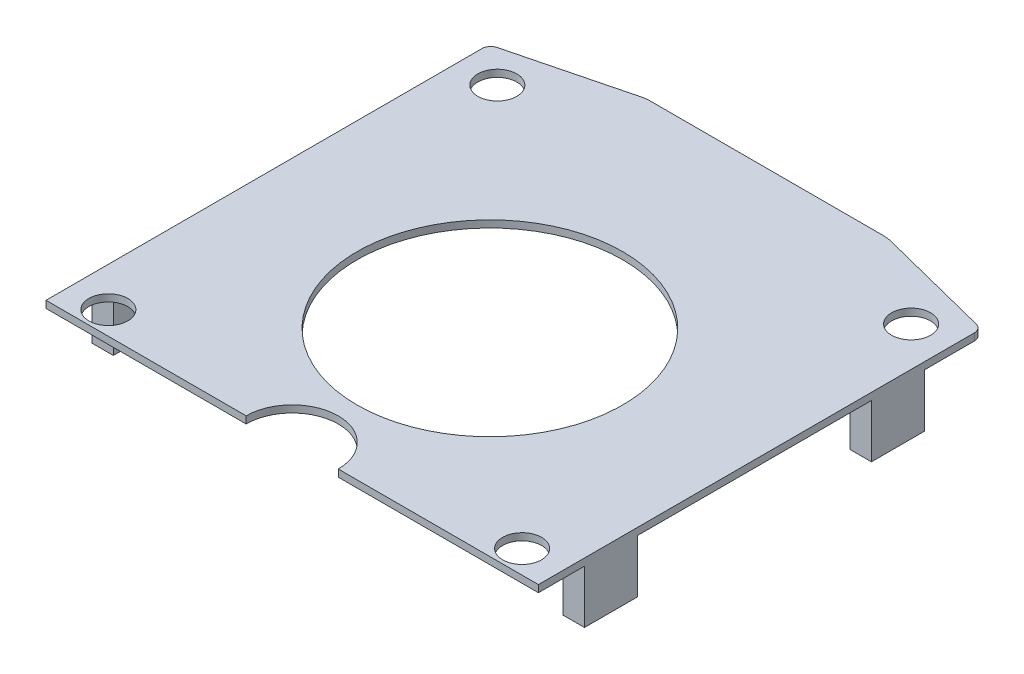
from build123d import *

# Parameters (mm, degrees)
SKETCH1_W           = 13.9
SKETCH1_H           = 0.75
BOSS_EXTRUDE1_DEPTH = 0.2
SKETCH2_R           = 0.55
SKETCH2_R_2         = 3.75
CUT_EXTRUDE1_DEPTH  = 0.3
CUT_EXTRUDE2_DEPTH  = 0.3
SKETCH6_W           = 1.5
SKETCH6_H           = 1.5
BOSS_EXTRUDE2_DEPTH = 0.6
SKETCH7_W           = 0.6
SKETCH7_H           = 1.5
BOSS_EXTRUDE3_DEPTH = 1.5


with BuildPart() as part:
    # Sketch1 → Boss-Extrude1 (new body)
    with BuildSketch(Plane(origin=(0, 0, 0), x_dir=(1, 0, 0), z_dir=(0, 1, 0))):
        with BuildLine():
            Line((-13.9, 12.65), (0, 12.65))
            Line((0, 12.65), (0, 24.20560625))
            ThreePointArc((0, 24.20560625), (-0.052642553, 24.359066467), (-0.188400305, 24.447898383))
            Line((-0.188400305, 24.447898383), (-3.418729556, 25.269168531))
            ThreePointArc((-3.418729556, 25.269168531), (-3.540968219, 25.292262196), (-3.665128335, 25.3))
            Line((-3.665128335, 25.3), (-10.234871665, 25.3))
            ThreePointArc((-10.234871665, 25.3), (-10.359031781, 25.292262196), (-10.481270444, 25.269168531))
            Line((-10.481270444, 25.269168531), (-13.711599695, 24.447898383))
            ThreePointArc((-13.711599695, 24.447898383), (-13.847357447, 24.359066467), (-13.9, 24.20560625))
            Line((-13.9, 24.20560625), (-13.9, 12.65))
        make_face()
        with Locations((-6.95, 12.275)):
            Rectangle(SKETCH1_W, SKETCH1_H)
    extrude(amount=BOSS_EXTRUDE1_DEPTH)

    # Sketch2 → Cut-Extrude1 (cut)
    with BuildSketch(Plane(origin=(0, 0.2, 0), x_dir=(1, 0, 0), z_dir=(0, 1, 0))):
        with Locations((-1.11, 23.53)):
            Circle(SKETCH2_R)
        with Locations((-1.11, 12.55)):
            Circle(SKETCH2_R)
        with Locations((-12.79, 23.53)):
            Circle(SKETCH2_R)
        with Locations((-12.79, 12.55)):
            Circle(SKETCH2_R)
        with Locations((-6.95, 17.48)):
            Circle(SKETCH2_R_2)
    extrude(amount=-CUT_EXTRUDE1_DEPTH, mode=Mode.SUBTRACT)

    # Sketch4 → Cut-Extrude2 (cut)
    with BuildSketch(Plane(origin=(0, 0.2, 0), x_dir=(1, 0, 0), z_dir=(0, 1, 0))):
        with BuildLine():
            Line((-5.65, 11.9), (-8.25, 11.9))
            ThreePointArc((-8.25, 11.9), (-6.95, 13.2), (-5.65, 11.9))
        make_face()
    extrude(amount=-CUT_EXTRUDE2_DEPTH, mode=Mode.SUBTRACT)

    # Sketch6 → Boss-Extrude2 (add)
    with BuildSketch(Plane(origin=(0, 0, 0), x_dir=(0, 0, -1), z_dir=(1, 0, 0))):
        with Locations((22.05, -0.75)):
            Rectangle(SKETCH6_W, SKETCH6_H)
        with Locations((13.95, -0.75)):
            Rectangle(SKETCH6_W, SKETCH6_H)
    extrude(amount=-BOSS_EXTRUDE2_DEPTH)

    # Sketch7 → Boss-Extrude3 (add)
    with BuildSketch(Plane.XZ):
        with Locations((-0.3, -22.05)):
            Rectangle(SKETCH7_W, SKETCH7_H)
        with Locations((-0.3, -13.95)):
            Rectangle(SKETCH7_W, SKETCH7_H)
        with Locations((-13.6, -13.95)):
            Rectangle(SKETCH7_W, SKETCH7_H)
        with Locations((-13.6, -22.05)):
            Rectangle(SKETCH7_W, SKETCH7_H)
    extrude(amount=BOSS_EXTRUDE3_DEPTH)


solid = part.part
